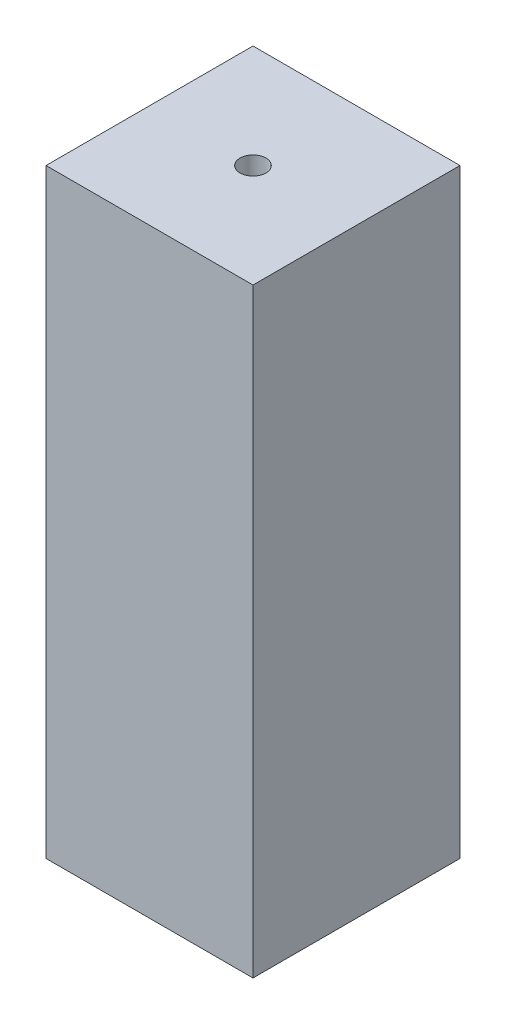
from build123d import *

# Parameters (mm, degrees)
SKETCH1_W           = 25.4
SKETCH1_H           = 25.4
BOSS_EXTRUDE1_DEPTH = 73.65
SKETCH2_R           = 1.59
CUT_EXTRUDE1_DEPTH  = 25.4


with BuildPart() as part:
    # Sketch1 → Boss-Extrude1 (new body)
    with BuildSketch(Plane(origin=(0, 0, 0), x_dir=(1, 0, 0), z_dir=(0, 1, 0))):
        Rectangle(SKETCH1_W, SKETCH1_H)
    extrude(amount=BOSS_EXTRUDE1_DEPTH)

    # Sketch2 → Cut-Extrude1 (cut)
    with BuildSketch(Plane(origin=(0, 73.65, 0), x_dir=(1, 0, 0), z_dir=(0, 1, 0))):
        Circle(SKETCH2_R)
    extrude(amount=-CUT_EXTRUDE1_DEPTH, mode=Mode.SUBTRACT)


solid = part.part
